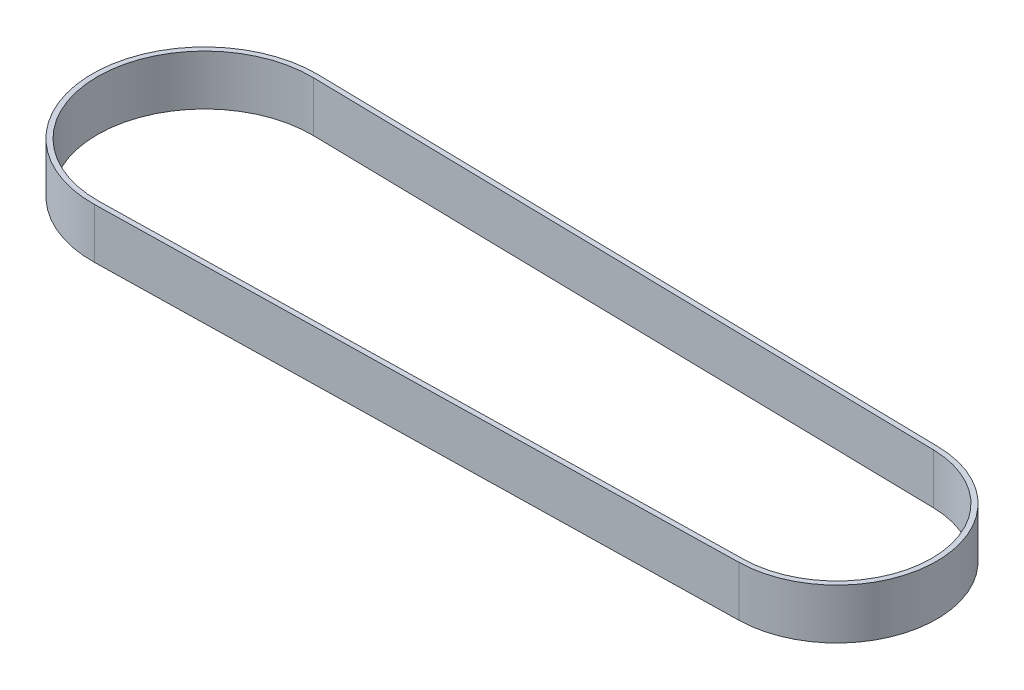
from build123d import *

# Parameters (mm, degrees)
BOSS_EXTRUDE1_DEPTH = 10


with BuildPart() as part:
    # Sketch1 → Boss-Extrude1 (new body)
    with BuildSketch(Plane(origin=(0, 0, 0), x_dir=(1, 0, 0), z_dir=(0, 1, 0))):
        with BuildLine():
            Line((0.434583333, 22.345774485), (126.386944444, 19.896237684))
            ThreePointArc((126.386944444, 19.896237684), (145.9, 0), (126.386944444, -19.896237684))
            Line((126.386944444, -19.896237684), (0.434583333, -22.345774485))
            ThreePointArc((0.434583333, -22.345774485), (-22.35, 0), (0.434583333, 22.345774485))
        make_face()
        with BuildLine():
            Line((0.415138889, 21.345963546), (126.3675, 18.896426746))
            ThreePointArc((126.3675, 18.896426746), (144.9, 0), (126.3675, -18.896426746))
            Line((126.3675, -18.896426746), (0.415138889, -21.345963546))
            ThreePointArc((0.415138889, -21.345963546), (-21.35, 0), (0.415138889, 21.345963546))
        make_face(mode=Mode.SUBTRACT)
    extrude(amount=BOSS_EXTRUDE1_DEPTH)


solid = part.part
